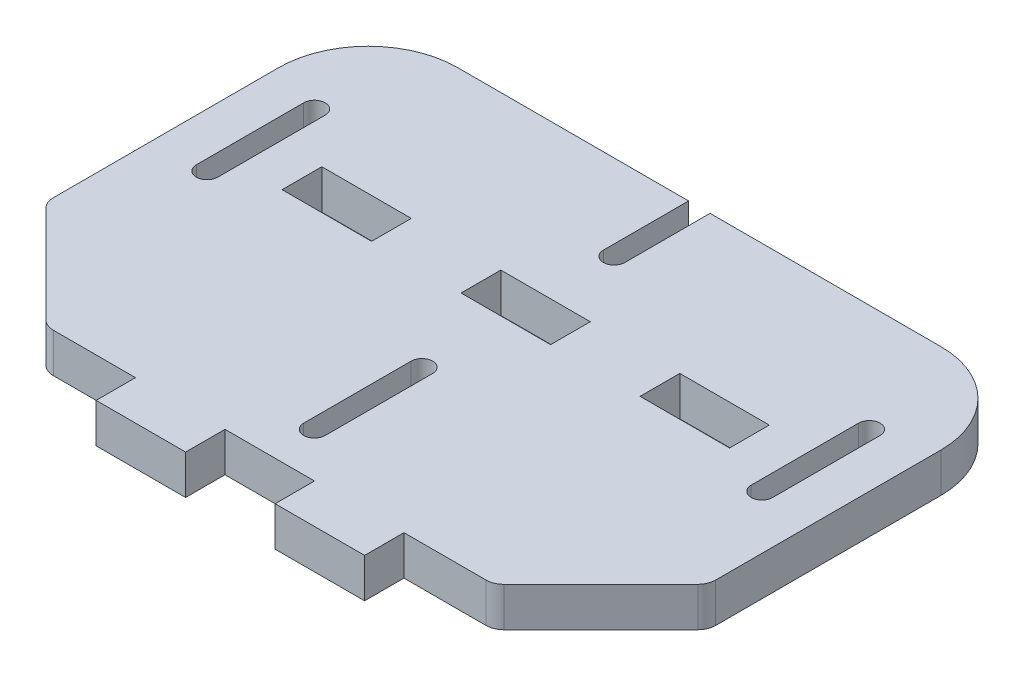
from build123d import *

# Parameters (mm, degrees)
BOSS_EXTRUDE6_DEPTH = 11
SKETCH4_W           = 25
SKETCH4_H           = 11
SKETCH4_H_2         = 11.1
CUT_EXTRUDE1_DEPTH  = 12
FILLET1_R           = 25
FILLET2_R           = 5


with BuildPart() as part:
    # Sketch1 → Boss-Extrude6 (new body)
    with BuildSketch(Plane(origin=(0, 0, 0), x_dir=(1, 0, 0), z_dir=(0, 1, 0))):
        with BuildLine():
            Line((0, -7.5), (125, -7.5))
            Line((125, -7.5), (125, 3.5))
            Line((125, 3.5), (155, 33.5))
            Line((155, 33.5), (155, 123.5))
            Line((155, 123.5), (65.5, 123.5))
            Line((65.5, 123.5), (65.5, 99.705746838))
            ThreePointArc((65.5, 99.705746838), (62.5, 96.705746838), (59.5, 99.705746838))
            Line((59.5, 99.705746838), (59.5, 123.5))
            Line((59.5, 123.5), (-30, 123.5))
            Line((-30, 123.5), (-30, 33.5))
            Line((-30, 33.5), (0, 3.5))
            Line((0, 3.5), (0, -7.5))
        make_face()
        with BuildLine():
            Line((137, 63.5), (137, 93.5))
            ThreePointArc((137, 93.5), (140, 96.5), (143, 93.5))
            Line((143, 93.5), (143, 63.5))
            ThreePointArc((143, 63.5), (140, 60.5), (137, 63.5))
        make_face(mode=Mode.SUBTRACT)
        with BuildLine():
            Line((-18, 63.5), (-18, 93.5))
            ThreePointArc((-18, 93.5), (-15, 96.5), (-12, 93.5))
            Line((-12, 93.5), (-12, 63.5))
            ThreePointArc((-12, 63.5), (-15, 60.5), (-18, 63.5))
        make_face(mode=Mode.SUBTRACT)
        with BuildLine():
            Line((59.5, 16), (59.5, 46))
            ThreePointArc((59.5, 46), (62.5, 49), (65.5, 46))
            Line((65.5, 46), (65.5, 16))
            ThreePointArc((65.5, 16), (62.5, 13), (59.5, 16))
        make_face(mode=Mode.SUBTRACT)
    extrude(amount=BOSS_EXTRUDE6_DEPTH)

    # Sketch4 → Cut-Extrude1 (cut, through all)
    with BuildSketch(Plane(origin=(0, 11, 0), x_dir=(1, 0, 0), z_dir=(0, 1, 0))):
        with Locations((12.5, -2)):
            Rectangle(SKETCH4_W, SKETCH4_H)
        with Locations((62.5, -2)):
            Rectangle(SKETCH4_W, SKETCH4_H)
        with Locations((12.5, 75)):
            Rectangle(SKETCH4_W, SKETCH4_H_2)
        with Locations((112.5, -2)):
            Rectangle(SKETCH4_W, SKETCH4_H)
        with Locations((62.5, 75)):
            Rectangle(SKETCH4_W, SKETCH4_H_2)
        with Locations((112.5, 75)):
            Rectangle(SKETCH4_W, SKETCH4_H_2)
    extrude(amount=-CUT_EXTRUDE1_DEPTH, mode=Mode.SUBTRACT)

    # Fillet1
    fillet1_edges = [part.edges().sort_by_distance(p)[0] for p in [
        (-30, 5.5, -123.5),
        (155, 5.5, -123.5),
    ]]
    fillet(fillet1_edges, radius=FILLET1_R)

    # Fillet2
    fillet2_edges = [part.edges().sort_by_distance(p)[0] for p in [
        (0, 5.5, -3.5),
        (-30, 5.5, -33.5),
        (155, 5.5, -33.5),
        (125, 5.5, -3.5),
    ]]
    fillet(fillet2_edges, radius=FILLET2_R)


solid = part.part
